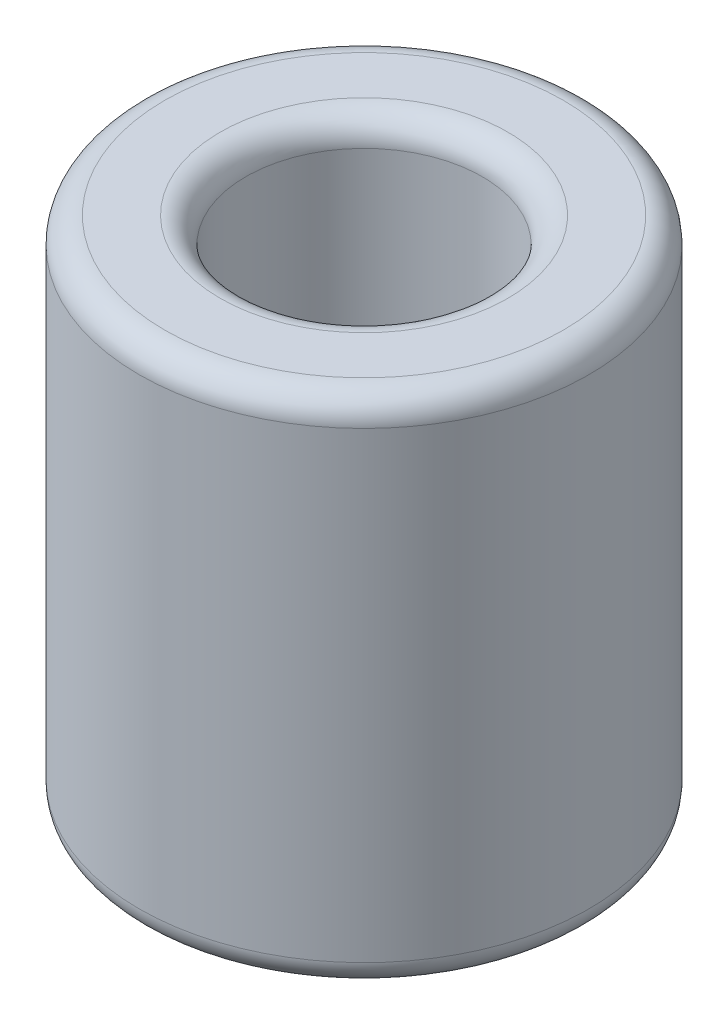
from build123d import *

# Parameters (mm, degrees)
SKETCH1_R           = 4.375
SKETCH1_R_2         = 2.3
BOSS_EXTRUDE1_DEPTH = 10
FILLET1_R           = 0.5


with BuildPart() as part:
    # Sketch1 → Boss-Extrude1 (new body)
    with BuildSketch(Plane(origin=(0, 0, 0), x_dir=(1, 0, 0), z_dir=(0, 1, 0))):
        with Locations(Location((0, 0, 0), (0, 0, 270))):  # turned: the seam where the file's is
            Circle(SKETCH1_R)
        with Locations(Location((0, 0, 0), (0, 0, 270))):  # turned: the seam where the file's is
            Circle(SKETCH1_R_2, mode=Mode.SUBTRACT)
    extrude(amount=BOSS_EXTRUDE1_DEPTH)

    # Fillet1
    fillet1_edges = [part.edges().sort_by_distance(p)[0] for p in [
        (0, 0, -4.375),
        (0, 10, -4.375),
        (0, 0, -2.3),
        (0, 10, -2.3),
    ]]
    fillet(fillet1_edges, radius=FILLET1_R)


solid = part.part
